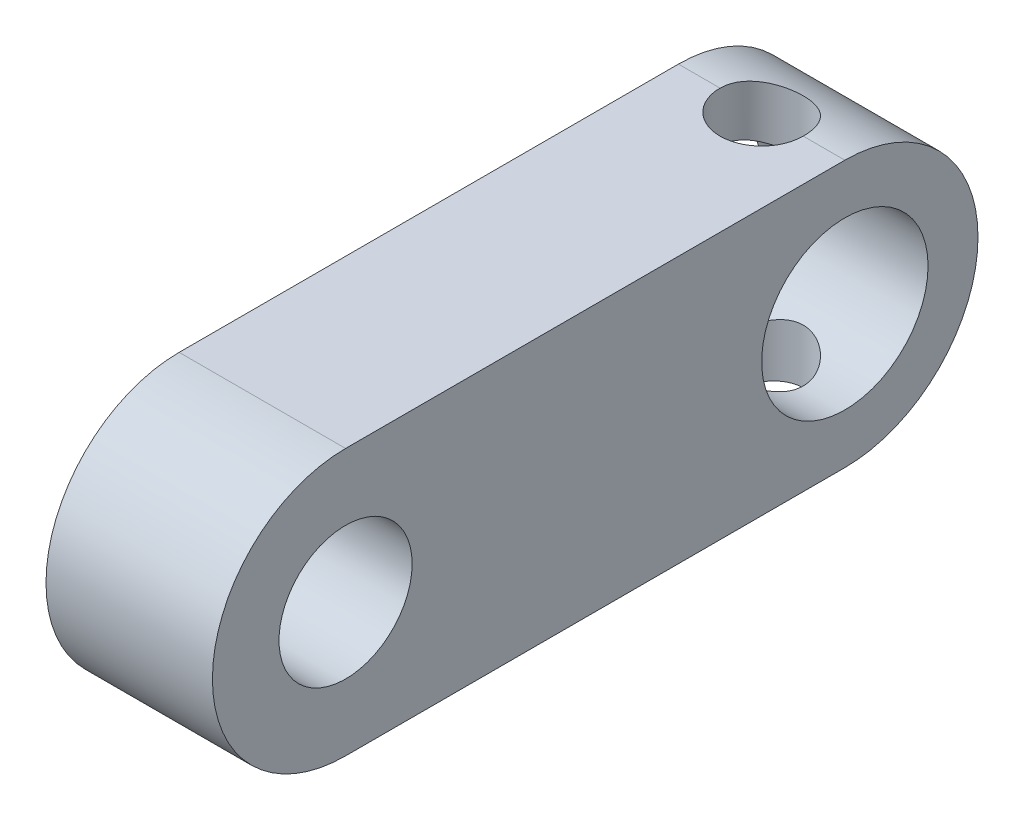
from build123d import *

# Parameters (mm, degrees)
SKETCH_1_R          = 4
SKETCH_1_R_2        = 5
EXTRUDE_1_DEPTH     = 10
SKETCH_2_R          = 2.5
CUT_EXTRUDE_1_DEPTH = 17


with BuildPart() as part:
    # 草图1 → 凸台-拉伸1 (new body)
    with BuildSketch(Plane(origin=(0, 0, 0), x_dir=(0, 0, -1), z_dir=(1, 0, 0))):
        with BuildLine():
            Line((15, 8), (-15, 8))
            ThreePointArc((-15, 8), (-23, 0), (-15, -8))
            Line((-15, -8), (15, -8))
            ThreePointArc((15, -8), (23, 0), (15, 8))
        make_face()
        with Locations((-15, 0)):
            Circle(SKETCH_1_R, mode=Mode.SUBTRACT)
        with Locations((15, 0)):
            Circle(SKETCH_1_R_2, mode=Mode.SUBTRACT)
    extrude(amount=EXTRUDE_1_DEPTH)

    # 草图2 → 切除-拉伸1 (cut, through all)
    with BuildSketch(Plane(origin=(0, 8, 0), x_dir=(1, 0, 0), z_dir=(0, 1, 0))):
        with Locations((5, 15)):
            Circle(SKETCH_2_R)
    extrude(amount=-CUT_EXTRUDE_1_DEPTH, mode=Mode.SUBTRACT)


solid = part.part
